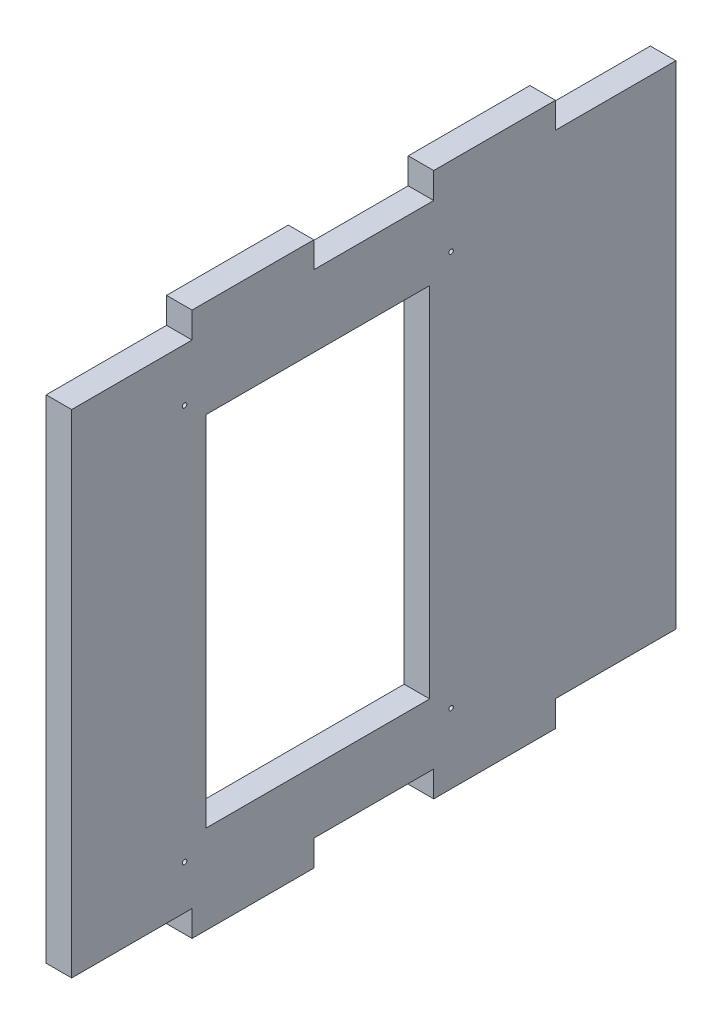
from build123d import *

# Parameters (mm, degrees)
SKETCH1_W           = 135
SKETCH1_H           = 122
BOSS_EXTRUDE1_DEPTH = 5.7
HOLE_W              = 50
HOLE_H              = 80
CUT_EXTRUDE2_DEPTH  = 70
SCREW_LOCATIONS_R   = 0.5
CUT_EXTRUDE3_DEPTH  = 52
CUT_EXTRUDE4_DEPTH  = 5.7


with BuildPart() as part:
    # Sketch1 → Boss-Extrude1 (new body)
    with BuildSketch(Plane(origin=(0, 0, 0), x_dir=(0, 0, -1), z_dir=(1, 0, 0))):
        with Locations((67.5, 61)):
            Rectangle(SKETCH1_W, SKETCH1_H)
    extrude(amount=BOSS_EXTRUDE1_DEPTH)

    # Hole → Cut-Extrude2 (cut)
    with BuildSketch(Plane(origin=(0, 0, 0), x_dir=(0, 0, -1), z_dir=(1, 0, 0))):
        with Locations((55, 60)):
            Rectangle(HOLE_W, HOLE_H)
    extrude(amount=CUT_EXTRUDE2_DEPTH, mode=Mode.SUBTRACT)

    # Screw Locations → Cut-Extrude3 (cut)
    with BuildSketch(Plane(origin=(0, 0, 0), x_dir=(0, 0, -1), z_dir=(1, 0, 0))):
        with Locations((25.23, 104.17)):
            Circle(SCREW_LOCATIONS_R)
        with Locations((84.77, 104.17)):
            Circle(SCREW_LOCATIONS_R)
        with Locations((25.23, 15.83)):
            Circle(SCREW_LOCATIONS_R)
        with Locations((84.77, 15.83)):
            Circle(SCREW_LOCATIONS_R)
    extrude(amount=CUT_EXTRUDE3_DEPTH, mode=Mode.SUBTRACT)

    # Sketch4 → Cut-Extrude4 (cut)
    with BuildSketch(Plane(origin=(0, 0, 0), x_dir=(0, 0, -1), z_dir=(1, 0, 0))):
        Polygon((0, 116), (26.9, 116), (26.9, 121.8), (54.1, 121.8), (54.1, 116), (80.9, 116), (80.9, 121.8), (108.1, 121.8), (108.1, 116), (135, 116), (135, 130), (0, 130), align=None)
        Polygon((0, -8), (0, 6), (26.9, 6), (26.9, 0.2), (54.1, 0.2), (54.1, 6), (80.9, 6), (80.9, 0.2), (108.1, 0.2), (108.1, 6), (135, 6), (135, -8), align=None)
    extrude(amount=CUT_EXTRUDE4_DEPTH, mode=Mode.SUBTRACT)


solid = part.part
